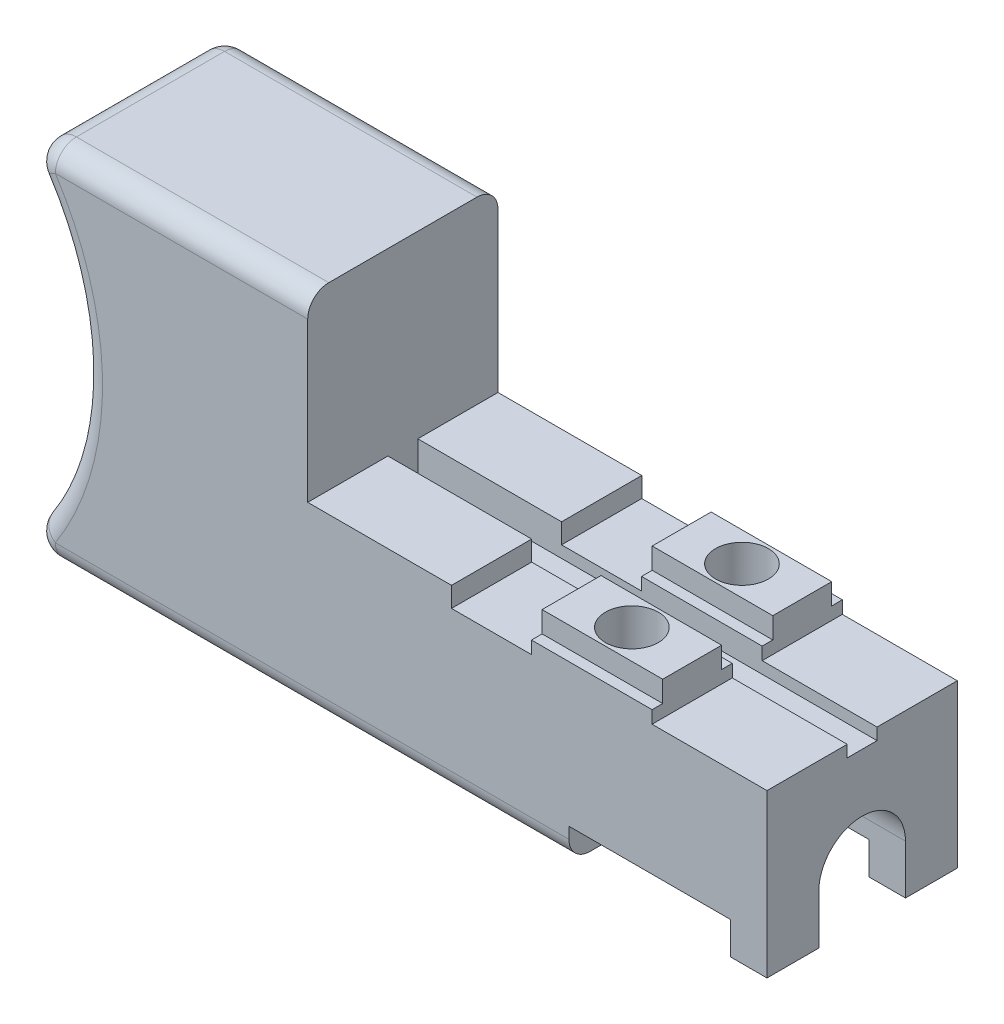
from build123d import *

# Parameters (mm, degrees)
BOSS_EXTRUDE1_DEPTH = 11.4808
SKETCH2_W           = 27.7114
SKETCH2_H           = 1.8034
CUT_EXTRUDE1_DEPTH  = 2.7432
SKETCH3_R           = 1.59385
CUT_EXTRUDE2_DEPTH  = 7.112
BOSS_EXTRUDE2_DEPTH = 11.4808
FILLET1_R           = 1.27
SKETCH5_W           = 7.2771
SKETCH5_H           = 0.64135
CUT_EXTRUDE3_DEPTH  = 1.27
CUT_EXTRUDE4_DEPTH  = 13.589


with BuildPart() as part:
    # Sketch1 → Boss-Extrude1 (new body)
    with BuildSketch(Plane.XY):
        Polygon((0, 0), (8.6741, 0), (8.6741, -1.2065), (13.5001, -1.2065), (13.5001, 0.8255), (20.7772, 0.8255), (20.7772, -1.2065), (27.7114, -1.2065), (27.7114, -11), (25.5016, -11), (25.5016, -9.0442), (15.7607, -9.0442), (15.7607, -11), (0, -11), align=None)
    extrude(amount=-BOSS_EXTRUDE1_DEPTH)

    # Sketch2 → Cut-Extrude1 (cut)
    with BuildSketch(Plane(origin=(0, 0.8255, 0), x_dir=(1, 0, 0), z_dir=(0, 1, 0))):
        with Locations((13.8557, 5.7404)):
            Rectangle(SKETCH2_W, SKETCH2_H)
    extrude(amount=-CUT_EXTRUDE1_DEPTH, mode=Mode.SUBTRACT)

    # Sketch3 → Cut-Extrude2 (cut)
    with BuildSketch(Plane(origin=(0, 0.8255, 0), x_dir=(1, 0, 0), z_dir=(0, 1, 0))):
        with Locations((17.13865, 9.06145)):
            Circle(SKETCH3_R)
        with Locations((17.13865, 2.41935)):
            Circle(SKETCH3_R)
    extrude(amount=-CUT_EXTRUDE2_DEPTH, mode=Mode.SUBTRACT)

    # Sketch4 → Boss-Extrude2 (add)
    with BuildSketch(Plane.XY):
        with BuildLine():
            Line((0, 10.844), (0, -11))
            Line((0, -11), (-17.78, -11))
            ThreePointArc((-17.78, -11), (-13.651034529, -0.078), (-17.78, 10.844))
            Line((-17.78, 10.844), (0, 10.844))
        make_face()
    extrude(amount=-BOSS_EXTRUDE2_DEPTH)

    # Fillet1
    fillet1_edges = [part.edges().sort_by_distance(p)[0] for p in [
        (-1.00965, -11, 0),
        (-1.00965, -11, -11.4808),
        (-8.89, 10.844, 0),
        (-13.651034529, -0.078, 0),
        (-13.651034529, -0.078, -11.4808),
        (-17.78, -11, -5.7404),
        (-8.89, 10.844, -11.4808),
        (-17.78, 10.844, -5.7404),
    ]]
    fillet(fillet1_edges, radius=FILLET1_R)

    # Sketch5 → Cut-Extrude3 (cut)
    with BuildSketch(Plane(origin=(0, 0.8255, 0), x_dir=(1, 0, 0), z_dir=(0, 1, 0))):
        with Locations((17.13865, 6.962775)):
            Rectangle(SKETCH5_W, SKETCH5_H)
        with Locations((17.13865, 11.160125)):
            Rectangle(SKETCH5_W, SKETCH5_H)
        with Locations((17.13865, 0.320675)):
            Rectangle(SKETCH5_W, SKETCH5_H)
        with Locations((17.13865, 4.518025)):
            Rectangle(SKETCH5_W, SKETCH5_H)
    extrude(amount=-CUT_EXTRUDE3_DEPTH, mode=Mode.SUBTRACT)

    # Sketch6 → Cut-Extrude4 (cut)
    with BuildSketch(Plane(origin=(27.7114, 0, 0), x_dir=(0, 0, -1), z_dir=(1, 0, 0))):
        with BuildLine():
            Line((3.1242, -11), (3.1242, -8.0282))
            ThreePointArc((3.1242, -8.0282), (5.7404, -5.412), (8.3566, -8.0282))
            Line((8.3566, -8.0282), (8.3566, -11))
            Line((8.3566, -11), (3.1242, -11))
        make_face()
    extrude(amount=-CUT_EXTRUDE4_DEPTH, mode=Mode.SUBTRACT)


solid = part.part
